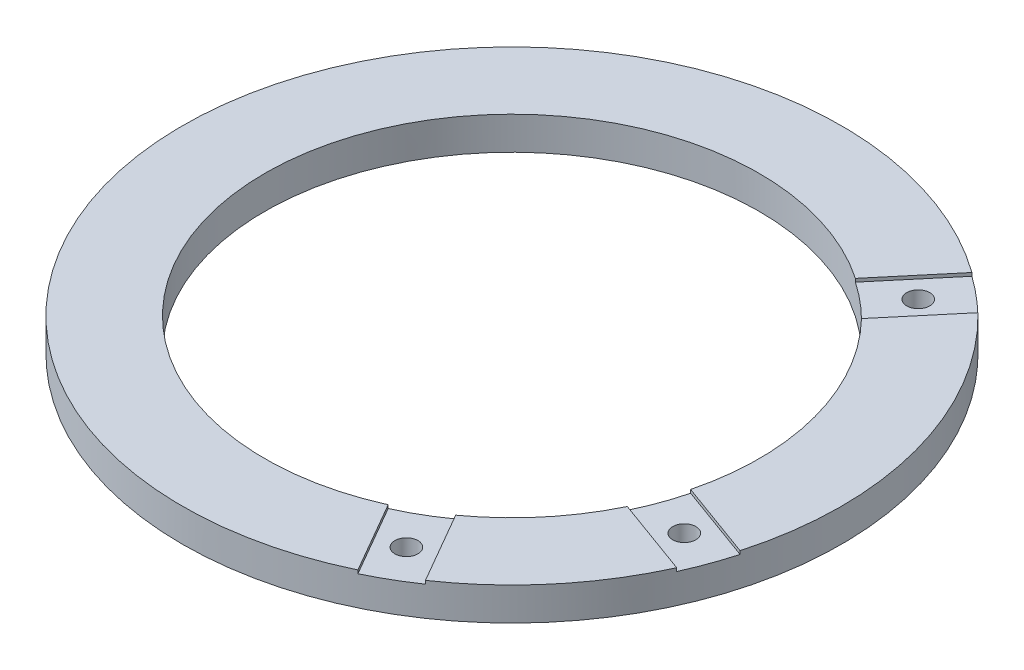
from build123d import *

# Parameters (mm, degrees)
ESQUISSE1_R                  = 200
ESQUISSE1_R_2                = 150
BOSS_EXTRU_1_DEPTH           = 20
TROU_TARAUD_M161_D           = 14
ENL_V_MAT_EXTRU_3_DEPTH      = 2
R_P_TITION_CIRCULAIRE1_COUNT = 2
R_P_TITION_CIRCULAIRE1_ANGLE = 70
R_P_TITION_CIRCULAIRE2_COUNT = 2
R_P_TITION_CIRCULAIRE2_ANGLE = 110


with BuildPart() as part:
    # Esquisse1 → Boss.-Extru.1 (new body)
    with BuildSketch(Plane(origin=(0, 0, 0), x_dir=(1, 0, 0), z_dir=(0, 1, 0))):
        with Locations(Location((0, 0, 0), (0, 0, 270))):  # turned: the seam where the file's is
            Circle(ESQUISSE1_R)
        with Locations(Location((0, 0, 0), (0, 0, 270))):  # turned: the seam where the file's is
            Circle(ESQUISSE1_R_2, mode=Mode.SUBTRACT)
    extrude(amount=BOSS_EXTRU_1_DEPTH)

    # Trou taraud_ M161 (through all)
    with Locations(Plane(origin=(0, 20, 0), x_dir=(1, 0, 0), z_dir=(0, 1, 0))):
        with Locations((112.487831695, 134.057777546)):
            trou_taraud_m161 = Hole(TROU_TARAUD_M161_D / 2)

    # Esquisse4 → Enl_v. mat.-Extru.3 (cut)
    with BuildSketch(Plane(origin=(0, 20, 0), x_dir=(1, 0, 0), z_dir=(0, 1, 0))):
        Polygon((-11.490666647, 9.641814145), (11.490666647, -9.641814145), (140.048188584, 143.567074478), (117.066855291, 162.850702769), align=None)
    enl_v_mat_extru_3 = extrude(amount=-ENL_V_MAT_EXTRU_3_DEPTH, mode=Mode.SUBTRACT)

    # R_p_tition circulaire1: Trou taraud_ M161, Enl_v. mat.-Extru.3 ×2 about axis
    r_p_tition_circulaire1_axis = Axis((0, 0, 0), (0, -1, 0))
    add([trou_taraud_m161.rotate(r_p_tition_circulaire1_axis, i * R_P_TITION_CIRCULAIRE1_ANGLE / (R_P_TITION_CIRCULAIRE1_COUNT - 1)) for i in range(1, R_P_TITION_CIRCULAIRE1_COUNT)], mode=Mode.SUBTRACT)
    add([enl_v_mat_extru_3.rotate(r_p_tition_circulaire1_axis, i * R_P_TITION_CIRCULAIRE1_ANGLE / (R_P_TITION_CIRCULAIRE1_COUNT - 1)) for i in range(1, R_P_TITION_CIRCULAIRE1_COUNT)], mode=Mode.SUBTRACT)

    # R_p_tition circulaire2: Trou taraud_ M161, Enl_v. mat.-Extru.3 ×2 about axis
    r_p_tition_circulaire2_axis = Axis((0, 0, 0), (0, -1, 0))
    add([trou_taraud_m161.rotate(r_p_tition_circulaire2_axis, i * R_P_TITION_CIRCULAIRE2_ANGLE / (R_P_TITION_CIRCULAIRE2_COUNT - 1)) for i in range(1, R_P_TITION_CIRCULAIRE2_COUNT)], mode=Mode.SUBTRACT)
    add([enl_v_mat_extru_3.rotate(r_p_tition_circulaire2_axis, i * R_P_TITION_CIRCULAIRE2_ANGLE / (R_P_TITION_CIRCULAIRE2_COUNT - 1)) for i in range(1, R_P_TITION_CIRCULAIRE2_COUNT)], mode=Mode.SUBTRACT)


solid = part.part
